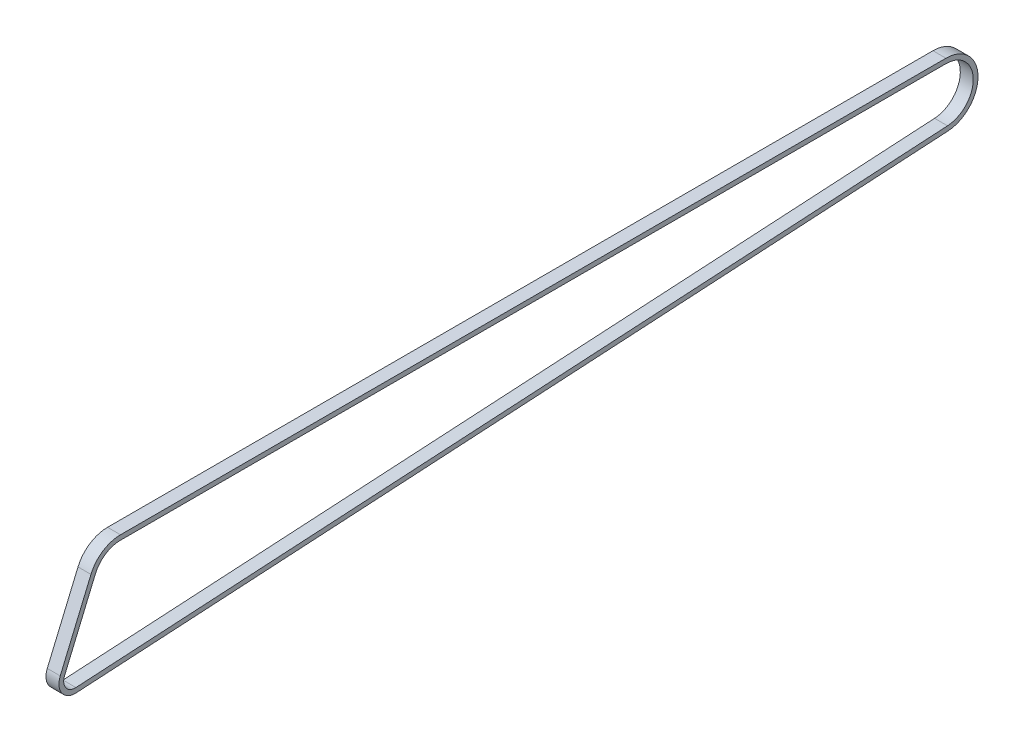
from build123d import *

# Parameters (mm, degrees)
SKETCH3_W = 6
SKETCH3_H = 2.2


with BuildPart() as part:
    # Sweep1: sweep along a path in Sketch1
    with BuildLine(Plane(origin=(0, 0, 0), x_dir=(0, 0, -1), z_dir=(1, 0, 0))) as sweep1_path:
        Line((0.31090006, -5.3474047), (403.879965212, 18.116247973))
        ThreePointArc((403.879965212, 18.116247973), (415.790396806, 31.112194288), (403.14572952, 43.394921614))
        Line((403.14572952, 43.394921614), (20.942535542, 43.394921614))
        ThreePointArc((20.942535542, 43.394921614), (13.956361094, 41.290814966), (9.294242947, 35.678457834))
        Line((9.294242947, 35.678457834), (-4.932278427, 2.089024985))
        ThreePointArc((-4.932278427, 2.089024985), (-4.377716999, -3.086582212), (0.31090006, -5.3474047))
    # Sketch3 → Sweep1 (sweep)
    with BuildSketch(Plane(origin=(0, 2.089024985, 4.932278427), x_dir=(1, 0, 0), z_dir=(0, -0.920813644, 0.390002863))):
        with Locations((0, 1.1)):
            Rectangle(SKETCH3_W, SKETCH3_H)
    sweep(path=sweep1_path.line)


solid = part.part
